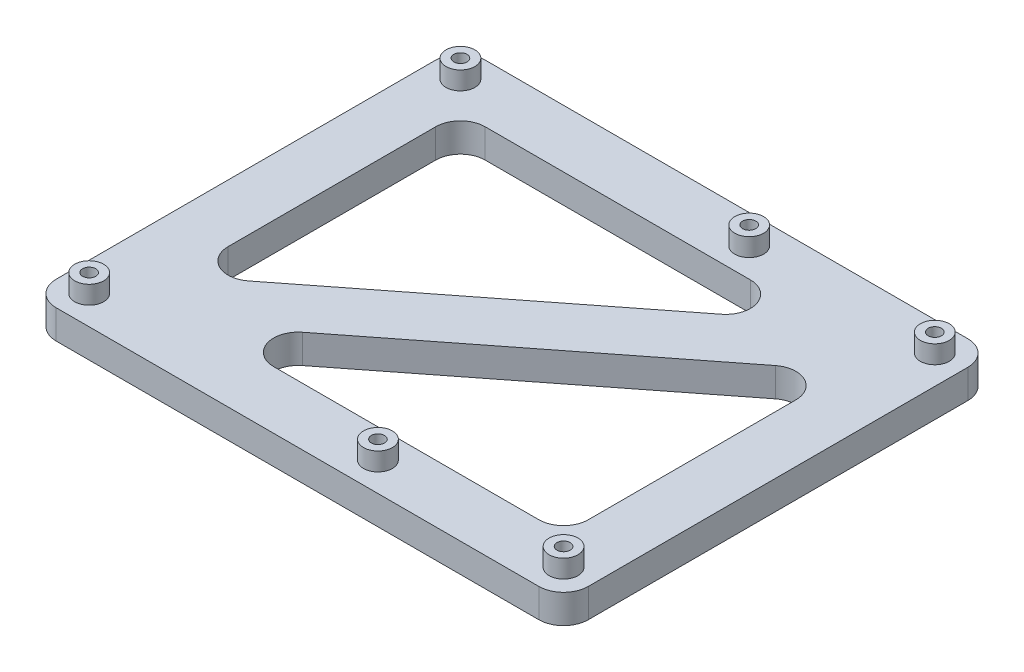
from build123d import *

# Parameters (mm, degrees)
SKETCH1_W           = 129
SKETCH1_H           = 104
SKETCH1_R           = 3.5
BOSS_EXTRUDE1_DEPTH = 7
FILLET1_R           = 6
SKETCH1_3_R         = 3.5
SKETCH1_3_R_2       = 1.6
BOSS_EXTRUDE2_DEPTH = 11.4
SKETCH2_R           = 1.6
CUT_EXTRUDE1_DEPTH  = 5


with BuildPart() as part:
    # Sketch1 → Boss-Extrude1 (new body)
    with BuildSketch(Plane(origin=(0, 0, 0), x_dir=(1, 0, 0), z_dir=(0, 1, 0))):
        Rectangle(SKETCH1_W, SKETCH1_H)
        with Locations((-57.5, -45)):
            Circle(SKETCH1_R, mode=Mode.SUBTRACT)
        with Locations((12.5, -45)):
            Circle(SKETCH1_R, mode=Mode.SUBTRACT)
        with Locations((57.5, -45)):
            Circle(SKETCH1_R, mode=Mode.SUBTRACT)
        Polygon((50.5, 30.63290669), (50.5, -38), (-37.197602993, -38), align=None, mode=Mode.SUBTRACT)
        Polygon((37.197602993, 38), (-50.5, -30.63290669), (-50.5, 38), align=None, mode=Mode.SUBTRACT)
        with Locations((-57.5, 45)):
            Circle(SKETCH1_R, mode=Mode.SUBTRACT)
        with Locations((12.5, 45)):
            Circle(SKETCH1_R, mode=Mode.SUBTRACT)
        with Locations((57.5, 45)):
            Circle(SKETCH1_R, mode=Mode.SUBTRACT)
    extrude(amount=BOSS_EXTRUDE1_DEPTH)

    # Fillet1
    fillet1_edges = [part.edges().sort_by_distance(p)[0] for p in [
        (-64.5, 3.5, -52),
        (64.5, 3.5, -52),
        (64.5, 3.5, 52),
        (-37.197602993, 3.5, 38),
        (50.5, 3.5, 38),
        (50.5, 3.5, -30.63290669),
        (-50.5, 3.5, 30.63290669),
        (37.197602993, 3.5, -38),
        (-64.5, 3.5, 52),
        (-50.5, 3.5, -38),
    ]]
    fillet(fillet1_edges, radius=FILLET1_R)

    # Sketch1_3 → Boss-Extrude2 (add)
    # profile 1 of 6: a face of its own
    with BuildSketch(Plane(origin=(0, 0, 0), x_dir=(1, 0, 0), z_dir=(0, 1, 0))):
        with Locations((-57.5, 45)):
            Circle(SKETCH1_3_R)
        with Locations((-57.5, 45)):
            Circle(SKETCH1_3_R_2, mode=Mode.SUBTRACT)
    # profile 2 of 6: a face of its own
    with BuildSketch(Plane(origin=(0, 0, 0), x_dir=(1, 0, 0), z_dir=(0, 1, 0))):
        with Locations((12.5, 45)):
            Circle(SKETCH1_3_R)
        with Locations((12.5, 45)):
            Circle(SKETCH1_3_R_2, mode=Mode.SUBTRACT)
    # profile 3 of 6: a face of its own
    with BuildSketch(Plane(origin=(0, 0, 0), x_dir=(1, 0, 0), z_dir=(0, 1, 0))):
        with Locations((57.5, 45)):
            Circle(SKETCH1_3_R)
        with Locations((57.5, 45)):
            Circle(SKETCH1_3_R_2, mode=Mode.SUBTRACT)
    # profile 4 of 6: a face of its own
    with BuildSketch(Plane(origin=(0, 0, 0), x_dir=(1, 0, 0), z_dir=(0, 1, 0))):
        with Locations((-57.5, -45)):
            Circle(SKETCH1_3_R)
        with Locations((-57.5, -45)):
            Circle(SKETCH1_3_R_2, mode=Mode.SUBTRACT)
    # profile 5 of 6: a face of its own
    with BuildSketch(Plane(origin=(0, 0, 0), x_dir=(1, 0, 0), z_dir=(0, 1, 0))):
        with Locations((12.5, -45)):
            Circle(SKETCH1_3_R)
        with Locations((12.5, -45)):
            Circle(SKETCH1_3_R_2, mode=Mode.SUBTRACT)
    # profile 6 of 6: a face of its own
    with BuildSketch(Plane(origin=(0, 0, 0), x_dir=(1, 0, 0), z_dir=(0, 1, 0))):
        with Locations((57.5, -45)):
            Circle(SKETCH1_3_R)
        with Locations((57.5, -45)):
            Circle(SKETCH1_3_R_2, mode=Mode.SUBTRACT)
    extrude(amount=BOSS_EXTRUDE2_DEPTH)

    # Sketch2 → Cut-Extrude1 (cut)
    # profile 1 of 6: a face of its own
    with BuildSketch(Plane.XZ):
        Polygon((-54.324573519, 45), (-55.91228676, 47.75), (-59.08771324, 47.75), (-60.675426481, 45), (-59.08771324, 42.25), (-55.91228676, 42.25), align=None)
        with Locations((-57.5, 45)):
            Circle(SKETCH2_R, mode=Mode.SUBTRACT)
    # profile 2 of 6: a face of its own
    with BuildSketch(Plane.XZ):
        Polygon((15.675426481, 45), (14.08771324, 47.75), (10.91228676, 47.75), (9.324573519, 45), (10.91228676, 42.25), (14.08771324, 42.25), align=None)
        with Locations((12.5, 45)):
            Circle(SKETCH2_R, mode=Mode.SUBTRACT)
    # profile 3 of 6: a face of its own
    with BuildSketch(Plane.XZ):
        Polygon((60.675426481, 45), (59.08771324, 47.75), (55.91228676, 47.75), (54.324573519, 45), (55.91228676, 42.25), (59.08771324, 42.25), align=None)
        with Locations((57.5, 45)):
            Circle(SKETCH2_R, mode=Mode.SUBTRACT)
    # profile 4 of 6: a face of its own
    with BuildSketch(Plane.XZ):
        Polygon((-54.324573519, -45), (-55.91228676, -42.25), (-59.08771324, -42.25), (-60.675426481, -45), (-59.08771324, -47.75), (-55.91228676, -47.75), align=None)
        with Locations((-57.5, -45)):
            Circle(SKETCH2_R, mode=Mode.SUBTRACT)
    # profile 5 of 6: a face of its own
    with BuildSketch(Plane.XZ):
        Polygon((15.675426481, -45), (14.08771324, -42.25), (10.91228676, -42.25), (9.324573519, -45), (10.91228676, -47.75), (14.08771324, -47.75), align=None)
        with Locations((12.5, -45)):
            Circle(SKETCH2_R, mode=Mode.SUBTRACT)
    # profile 6 of 6: a face of its own
    with BuildSketch(Plane.XZ):
        Polygon((60.675426481, -45), (59.08771324, -42.25), (55.91228676, -42.25), (54.324573519, -45), (55.91228676, -47.75), (59.08771324, -47.75), align=None)
        with Locations((57.5, -45)):
            Circle(SKETCH2_R, mode=Mode.SUBTRACT)
    extrude(amount=-CUT_EXTRUDE1_DEPTH, mode=Mode.SUBTRACT)


solid = part.part
